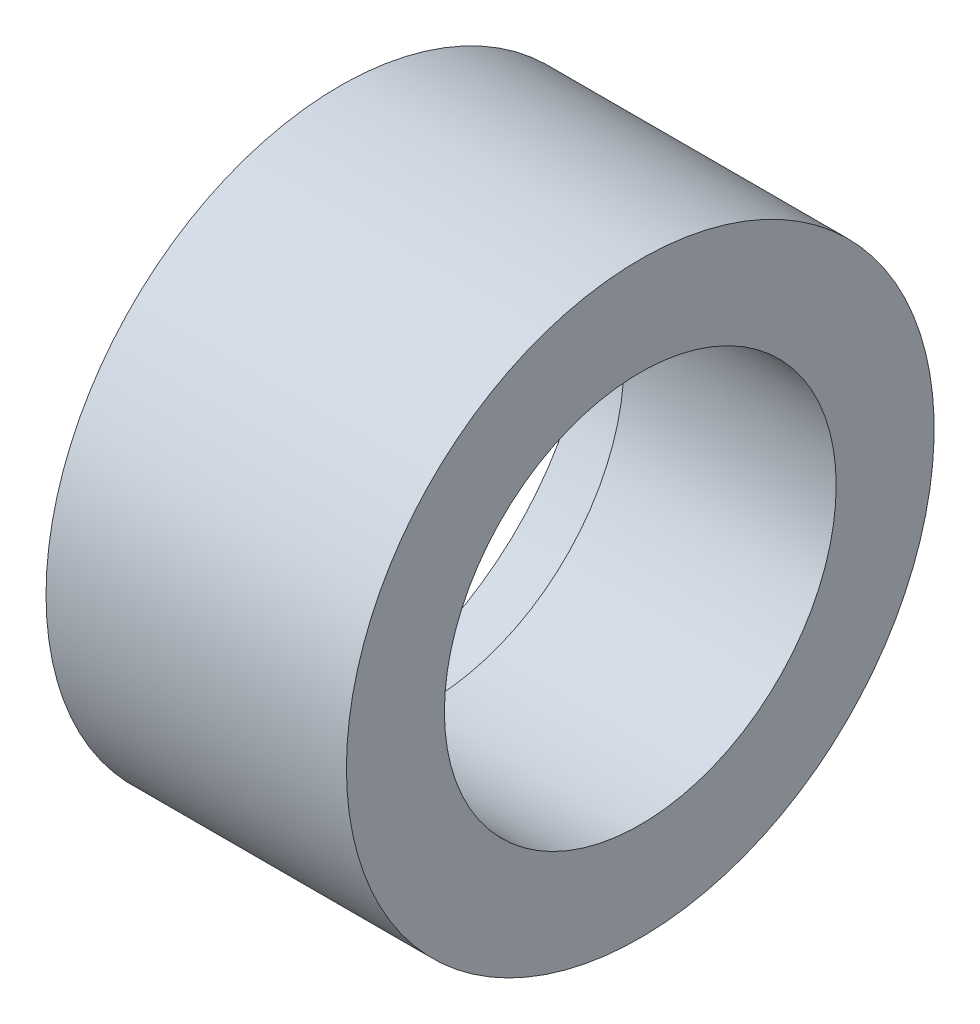
from build123d import *


with BuildPart() as part:
    # Sketch3 → Revolve1 (revolve)
    with BuildSketch(Plane.XY):
        Polygon((253.385153788, -140.873704322), (253.385153788, -142.573704322), (259.885153788, -142.573704322), (259.885153788, -140.857236748), (259.885153788, -139.573704322), (250.685153788, -139.573704322), (250.685153788, -140.873704322), align=None)
    revolve(axis=Axis((227.370475166, -148.573704322, 0), (1, 0, 0)))


solid = part.part
